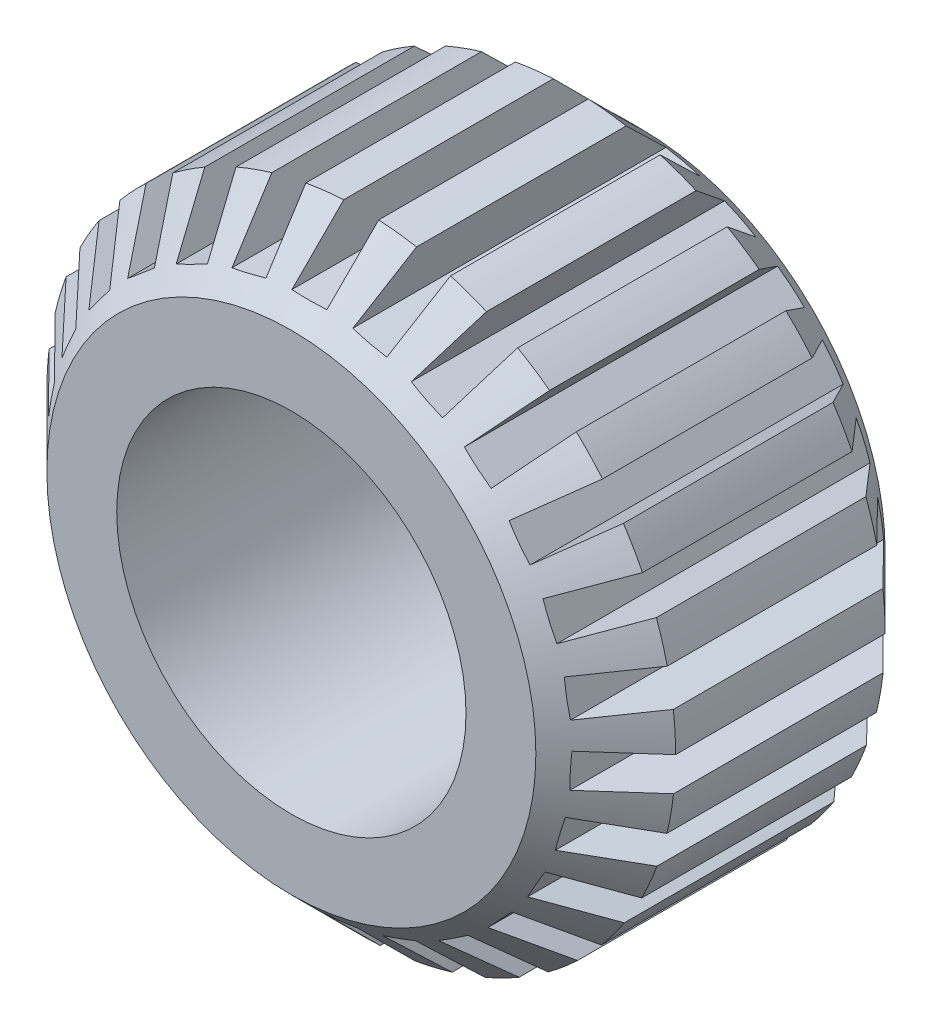
from build123d import *

# Parameters (mm, degrees)
SKETCH1_R           = 9
SKETCH1_R_2         = 5
BOSS_EXTRUDE1_DEPTH = 10
CHAMFER1_SIZE       = 2
CUT_EXTRUDE1_DEPTH  = 11
CIRPATTERN1_COUNT   = 27


with BuildPart() as part:
    # Sketch1 → Boss-Extrude1 (new body)
    with BuildSketch(Plane.XY):
        Circle(SKETCH1_R)
        Circle(SKETCH1_R_2, mode=Mode.SUBTRACT)
    extrude(amount=BOSS_EXTRUDE1_DEPTH)

    # Chamfer1
    chamfer1_edges = [part.edges().sort_by_distance(p)[0] for p in [
        (-9, 0, 10),
        (-9, 0, 0),
    ]]
    chamfer(chamfer1_edges, length=CHAMFER1_SIZE)

    # Sketch2 → Cut-Extrude1 (cut, through all)
    with BuildSketch(Plane.XY):
        with BuildLine():
            Line((-0.5, 7.5), (0.5, 7.5))
            Line((0.5, 7.5), (0.5, 8.986100378))
            ThreePointArc((0.5, 8.986100378), (0, 9), (-0.5, 8.986100378))
            Line((-0.5, 8.986100378), (-0.5, 7.5))
        make_face()
    cut_extrude1 = extrude(amount=CUT_EXTRUDE1_DEPTH, mode=Mode.SUBTRACT)

    # CirPattern1: Cut-Extrude1 ×27 about axis
    cirpattern1_axis = Axis((0, 0, 0), (0, 0, 1))
    for i in range(1, CIRPATTERN1_COUNT):
        add(cut_extrude1.rotate(cirpattern1_axis, i * 360 / CIRPATTERN1_COUNT), mode=Mode.SUBTRACT)


solid = part.part
